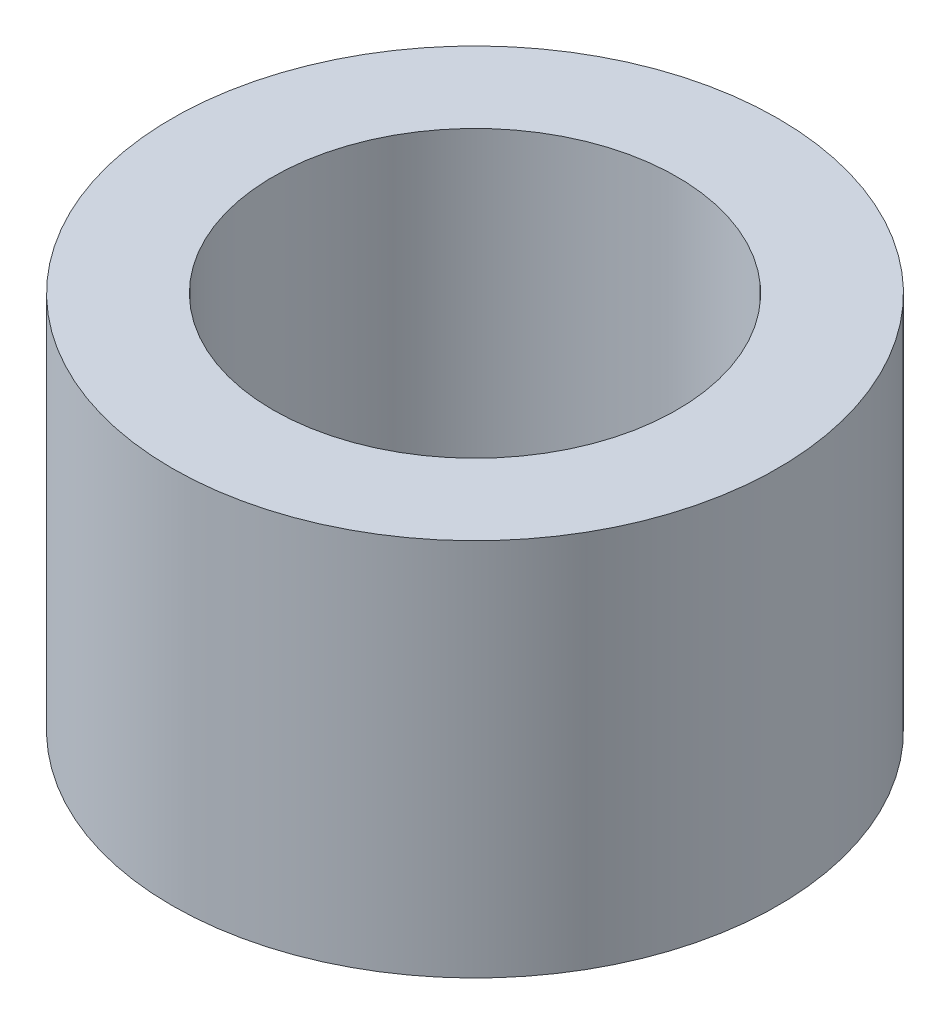
from build123d import *

# Parameters (mm, degrees)
SKETCH1_R           = 6
SKETCH1_R_2         = 4
BOSS_EXTRUDE1_DEPTH = 7.5


with BuildPart() as part:
    # Sketch1 → Boss-Extrude1 (new body)
    with BuildSketch(Plane(origin=(0, 0, 0), x_dir=(1, 0, 0), z_dir=(0, 1, 0))):
        Circle(SKETCH1_R)
        Circle(SKETCH1_R_2, mode=Mode.SUBTRACT)
    extrude(amount=BOSS_EXTRUDE1_DEPTH)


solid = part.part
